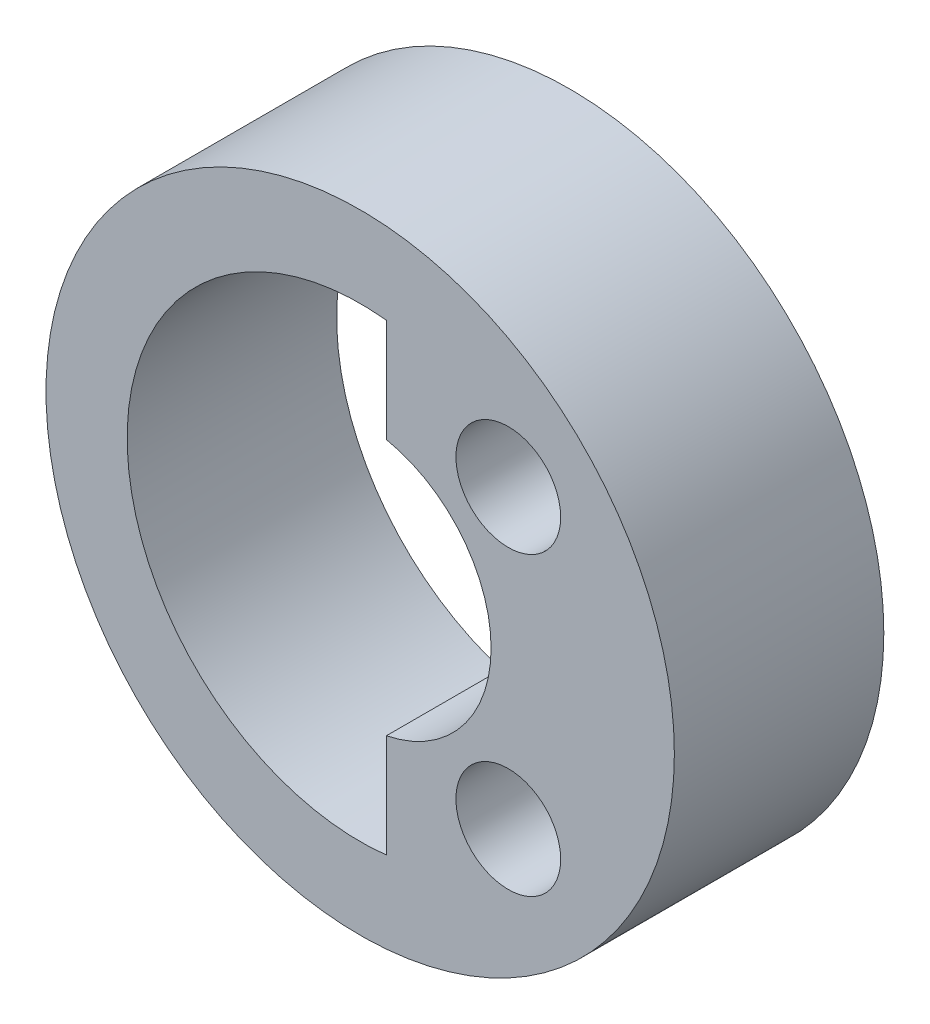
from build123d import *

# Parameters (mm, degrees)
BOSS_EXTRUDE1_START = -2.1
SKETCH1_R           = 3
BOSS_EXTRUDE1_DEPTH = 2
CUT_EXTRUDE1_DEPTH  = 3
SKETCH3_R           = 0.5
CUT_EXTRUDE2_DEPTH  = 3


with BuildPart() as part:
    # Sketch1 → Boss-Extrude1 (new body)
    with BuildSketch(Plane.XY.offset(BOSS_EXTRUDE1_START)):
        Circle(SKETCH1_R)
    extrude(amount=BOSS_EXTRUDE1_DEPTH)

    # Sketch2 → Cut-Extrude1 (cut, through all)
    with BuildSketch(Plane.XY.offset(-0.1)):
        with BuildLine():
            Line((0.25, 1.224744871), (0.25, 2.210910446))
            ThreePointArc((0.25, 2.210910446), (-2.225, 0), (0.25, -2.210910446))
            Line((0.25, -2.210910446), (0.25, -1.224744871))
            ThreePointArc((0.25, -1.224744871), (1.25, 0), (0.25, 1.224744871))
        make_face()
    extrude(amount=-CUT_EXTRUDE1_DEPTH, mode=Mode.SUBTRACT)

    # Sketch3 → Cut-Extrude2 (cut, through all)
    with BuildSketch(Plane.XY.offset(-0.1)):
        with Locations((1.414213562, 1.414213562)):
            Circle(SKETCH3_R)
    cut_extrude2 = extrude(amount=-CUT_EXTRUDE2_DEPTH, mode=Mode.SUBTRACT)

    # Mirror1: Cut-Extrude2 across plane
    add(cut_extrude2.mirror(Plane.ZX), mode=Mode.SUBTRACT)


solid = part.part
